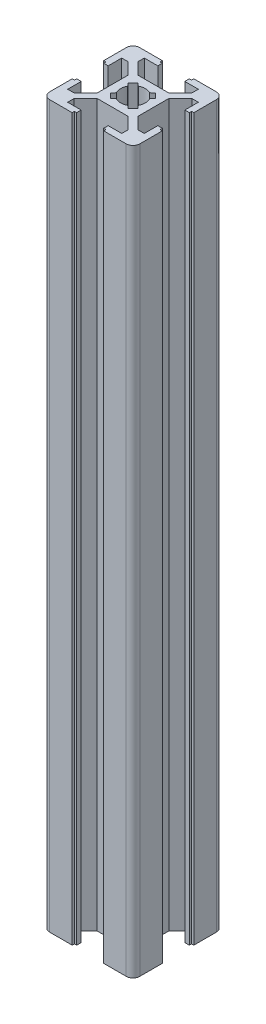
from build123d import *

# Parameters (mm, degrees)
DODANIE_WYCI_GNI_CIE1_DEPTH = 160


with BuildPart() as part:
    # Szkic1 → Dodanie-wyciągnięcie1 (new body)
    with BuildSketch(Plane(origin=(0, 0, 0), x_dir=(1, 0, 0), z_dir=(0, 1, 0))):
        with BuildLine():
            Line((-7.06, 6), (-4.5, 3.440546933))
            Line((-4.5, 3.440546933), (-4.5, 4.5))
            Line((-4.5, 4.5), (-3.440546933, 4.5))
            Line((-3.440546933, 4.5), (-6, 7.06))
            Line((-6, 7.06), (-6, 8.5))
            Line((-6, 8.5), (-3, 8.5))
            Line((-3, 8.5), (-3, 9.5))
            Line((-3, 9.5), (-3.5, 9.5))
            Line((-3.5, 9.5), (-3.5, 10))
            Line((-3.5, 10), (-8.5, 10))
            ThreePointArc((-8.5, 10), (-9.560660172, 9.560660172), (-10, 8.5))
            Line((-10, 8.5), (-10, 3.5))
            Line((-10, 3.5), (-9.5, 3.5))
            Line((-9.5, 3.5), (-9.5, 3))
            Line((-9.5, 3), (-8.5, 3))
            Line((-8.5, 3), (-8.5, 6))
            Line((-8.5, 6), (-7.06, 6))
        make_face()
        with BuildLine():
            Line((4.5, 4.5), (4.5, 3.440546933))
            Line((4.5, 3.440546933), (7.06, 6))
            Line((7.06, 6), (8.5, 6))
            Line((8.5, 6), (8.5, 3))
            Line((8.5, 3), (9.5, 3))
            Line((9.5, 3), (9.5, 3.5))
            Line((9.5, 3.5), (10, 3.5))
            Line((10, 3.5), (10, 8.5))
            ThreePointArc((10, 8.5), (9.560660172, 9.560660172), (8.5, 10))
            Line((8.5, 10), (3.5, 10))
            Line((3.5, 10), (3.5, 9.5))
            Line((3.5, 9.5), (3, 9.5))
            Line((3, 9.5), (3, 8.5))
            Line((3, 8.5), (6, 8.5))
            Line((6, 8.5), (6, 7.06))
            Line((6, 7.06), (3.440546933, 4.5))
            Line((3.440546933, 4.5), (4.5, 4.5))
        make_face()
        Polygon((3.440546933, -4.5), (4.5, -4.5), (4.5, -3.440546933), (4.5, 3.440546933), (4.5, 4.5), (3.440546933, 4.5), (-3.440546933, 4.5), (-4.5, 4.5), (-4.5, 3.440546933), (-4.5, -3.440546933), (-4.5, -4.5), (-3.440546933, -4.5), align=None)
        with BuildLine():
            Line((-3.00520382, 1.944543648), (-1.944543648, 3.00520382))
            Line((-1.944543648, 3.00520382), (-1.271309214, 2.438498079))
            ThreePointArc((-1.271309214, 2.438498079), (0, 2.75), (1.271309214, 2.438498079))
            Line((1.271309214, 2.438498079), (1.944543648, 3.00520382))
            Line((1.944543648, 3.00520382), (3.00520382, 1.944543648))
            Line((3.00520382, 1.944543648), (2.438498079, 1.271309214))
            ThreePointArc((2.438498079, 1.271309214), (2.670989491, 0.654457899), (2.75, 0))
            ThreePointArc((2.75, 0), (2.670989491, -0.654457899), (2.438498079, -1.271309214))
            Line((2.438498079, -1.271309214), (3.00520382, -1.944543648))
            Line((3.00520382, -1.944543648), (1.944543648, -3.00520382))
            Line((1.944543648, -3.00520382), (1.271309214, -2.438498079))
            ThreePointArc((1.271309214, -2.438498079), (0, -2.75), (-1.271309214, -2.438498079))
            Line((-1.271309214, -2.438498079), (-1.944543648, -3.00520382))
            Line((-1.944543648, -3.00520382), (-3.00520382, -1.944543648))
            Line((-3.00520382, -1.944543648), (-2.438498079, -1.271309214))
            ThreePointArc((-2.438498079, -1.271309214), (-2.75, 0), (-2.438498079, 1.271309214))
            Line((-2.438498079, 1.271309214), (-3.00520382, 1.944543648))
        make_face(mode=Mode.SUBTRACT)
        with BuildLine():
            Line((-6, -7.06), (-3.440546933, -4.5))
            Line((-3.440546933, -4.5), (-4.5, -4.5))
            Line((-4.5, -4.5), (-4.5, -3.440546933))
            Line((-4.5, -3.440546933), (-7.06, -6))
            Line((-7.06, -6), (-8.5, -6))
            Line((-8.5, -6), (-8.5, -3))
            Line((-8.5, -3), (-9.5, -3))
            Line((-9.5, -3), (-9.5, -3.5))
            Line((-9.5, -3.5), (-10, -3.5))
            Line((-10, -3.5), (-10, -8.5))
            ThreePointArc((-10, -8.5), (-9.560660172, -9.560660172), (-8.5, -10))
            Line((-8.5, -10), (-3.5, -10))
            Line((-3.5, -10), (-3.5, -9.5))
            Line((-3.5, -9.5), (-3, -9.5))
            Line((-3, -9.5), (-3, -8.5))
            Line((-3, -8.5), (-6, -8.5))
            Line((-6, -8.5), (-6, -7.06))
        make_face()
        with BuildLine():
            Line((4.5, -3.440546933), (4.5, -4.5))
            Line((4.5, -4.5), (3.440546933, -4.5))
            Line((3.440546933, -4.5), (6, -7.06))
            Line((6, -7.06), (6, -8.5))
            Line((6, -8.5), (3, -8.5))
            Line((3, -8.5), (3, -9.5))
            Line((3, -9.5), (3.5, -9.5))
            Line((3.5, -9.5), (3.5, -10))
            Line((3.5, -10), (8.5, -10))
            ThreePointArc((8.5, -10), (9.560660172, -9.560660172), (10, -8.5))
            Line((10, -8.5), (10, -3.5))
            Line((10, -3.5), (9.5, -3.5))
            Line((9.5, -3.5), (9.5, -3))
            Line((9.5, -3), (8.5, -3))
            Line((8.5, -3), (8.5, -6))
            Line((8.5, -6), (7.06, -6))
            Line((7.06, -6), (4.5, -3.440546933))
        make_face()
    extrude(amount=DODANIE_WYCI_GNI_CIE1_DEPTH)


solid = part.part
